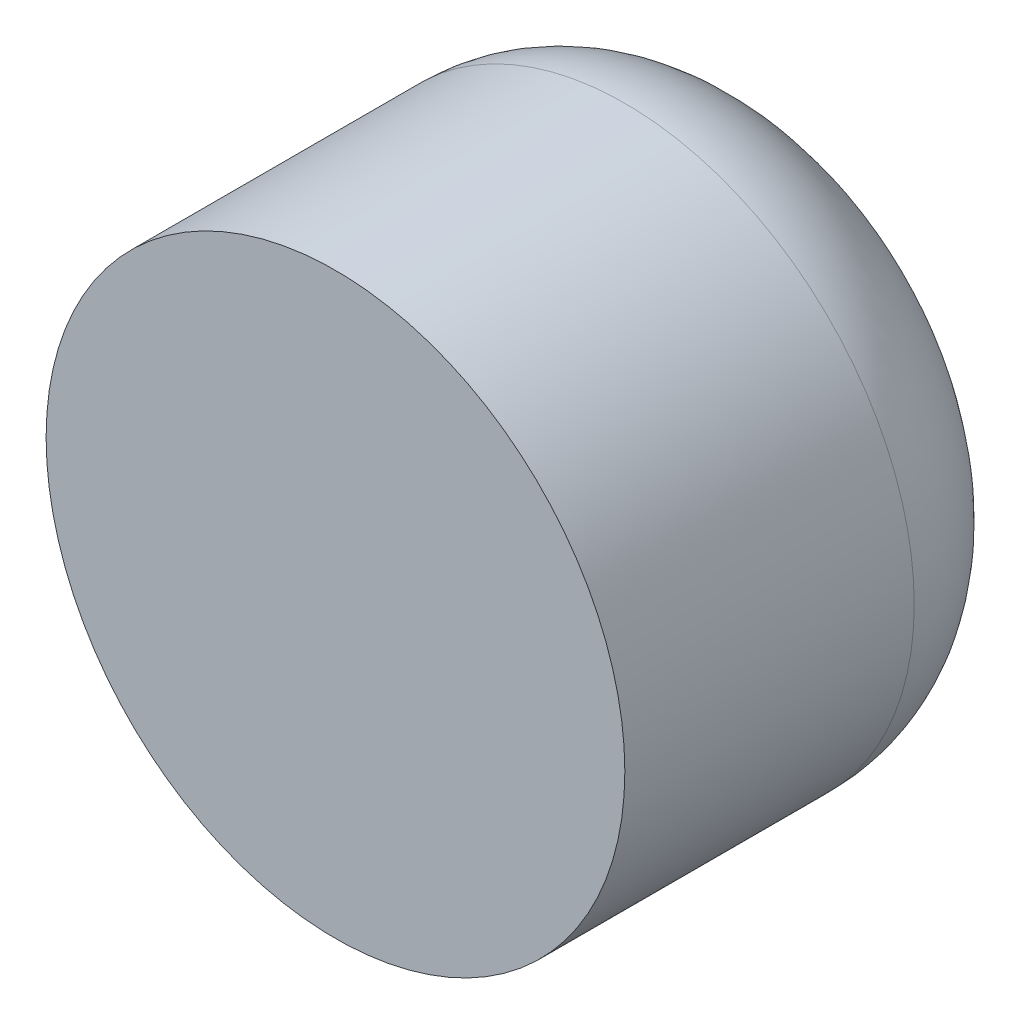
from build123d import *

# Parameters (mm, degrees)
SKETCH1_R           = 2
BOSS_EXTRUDE2_DEPTH = 3
CUT_EXTRUDE1_DEPTH  = 2
FILLET5_R           = 1


with BuildPart() as part:
    # Sketch1 → Boss-Extrude2 (new body)
    with BuildSketch(Plane.XY):
        with Locations((-4.574641492, 1.336412121)):
            Circle(SKETCH1_R)
    extrude(amount=BOSS_EXTRUDE2_DEPTH)

    # Sketch2 → Cut-Extrude1 (cut)
    with BuildSketch(Plane(origin=(0, 0, 0), x_dir=(-1, 0, 0), z_dir=(0, 0, -1))):
        Polygon((4.11056624, 2.130846028), (3.654603921, 1.331728117), (4.118679173, 0.53729421), (5.038716745, 0.541978214), (5.494679064, 1.341096126), (5.030603811, 2.135530033), align=None)
    extrude(amount=-CUT_EXTRUDE1_DEPTH, mode=Mode.SUBTRACT)

    # Fillet5
    fillet5_edges = [part.edges().sort_by_distance(p)[0] for p in [
        (-6.574641492, 1.336412121, 0),
    ]]
    fillet(fillet5_edges, radius=FILLET5_R)


solid = part.part
